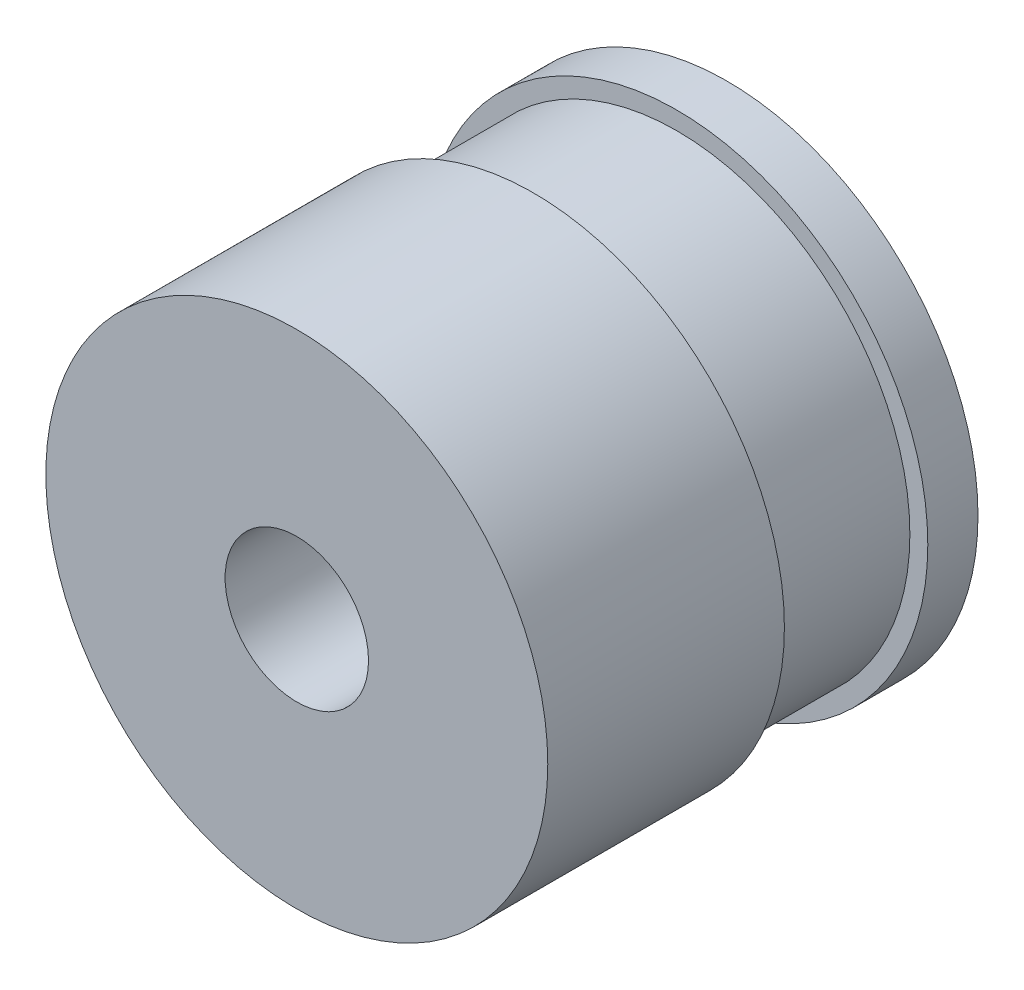
from build123d import *

# Parameters (mm, degrees)
ESQUISSE1_R        = 35
ESQUISSE1_R_2      = 10
BOSS_EXTRU_1_DEPTH = 7
ESQUISSE2_R        = 32.5
ESQUISSE2_R_2      = 10
BOSS_EXTRU_2_DEPTH = 20
ESQUISSE3_R        = 35
ESQUISSE3_R_2      = 10
BOSS_EXTRU_3_DEPTH = 33


with BuildPart() as part:
    # Esquisse1 → Boss.-Extru.1 (new body)
    with BuildSketch(Plane.XY):
        Circle(ESQUISSE1_R)
        Circle(ESQUISSE1_R_2, mode=Mode.SUBTRACT)
    extrude(amount=BOSS_EXTRU_1_DEPTH)

    # Esquisse2 → Boss.-Extru.2 (add)
    with BuildSketch(Plane.XY.offset(7)):
        Circle(ESQUISSE2_R)
        Circle(ESQUISSE2_R_2, mode=Mode.SUBTRACT)
    extrude(amount=BOSS_EXTRU_2_DEPTH)

    # Esquisse3 → Boss.-Extru.3 (add)
    with BuildSketch(Plane.XY.offset(27)):
        Circle(ESQUISSE3_R)
        Circle(ESQUISSE3_R_2, mode=Mode.SUBTRACT)
    extrude(amount=BOSS_EXTRU_3_DEPTH)


solid = part.part
